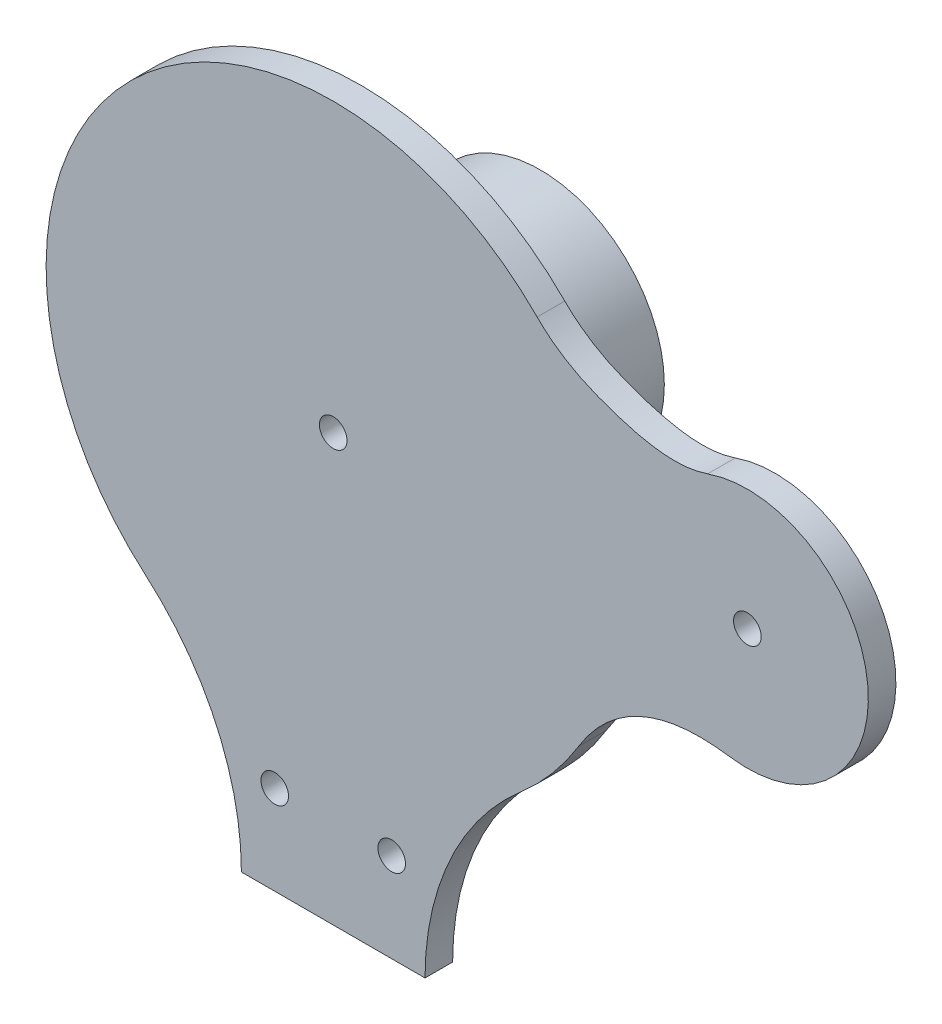
from build123d import *

# Parameters (mm, degrees)
SKETCH1_R           = 2.54
BOSS_EXTRUDE1_DEPTH = 5.08
SKETCH2_R           = 22.825529453
BOSS_EXTRUDE2_DEPTH = 33.02
SKETCH3_R           = 2.54
CUT_EXTRUDE1_DEPTH  = 39.1
BOSS_EXTRUDE3_DEPTH = 5.08
SKETCH5_R           = 2.54
CUT_EXTRUDE2_DEPTH  = 39.1


with BuildPart() as part:
    # Sketch1 → Boss-Extrude1 (new body)
    with BuildSketch(Plane.XY):
        with BuildLine():
            Line((-16.891, -131.282672274), (16.891, -131.282672274))
            ThreePointArc((16.891, -131.282672274), (19.601252021, -114.911473805), (27.442816508, -100.287128633))
            ThreePointArc((27.442816508, -100.287128633), (30.785280347, -96.37410804), (34.5064888, -92.819336271))
            ThreePointArc((34.5064888, -92.819336271), (0, 0), (-34.5064888, -92.819336271))
            ThreePointArc((-34.5064888, -92.819336271), (-30.785280347, -96.37410804), (-27.442816508, -100.287128633))
            ThreePointArc((-27.442816508, -100.287128633), (-19.601252021, -114.911473805), (-16.891, -131.282672274))
        make_face()
        with Locations((-10.756405179, -114.872047193)):
            Circle(SKETCH1_R, mode=Mode.SUBTRACT)
        with Locations((10.756405179, -114.872047193)):
            Circle(SKETCH1_R, mode=Mode.SUBTRACT)
    extrude(amount=BOSS_EXTRUDE1_DEPTH)

    # Sketch2 → Boss-Extrude2 (add)
    with BuildSketch(Plane(origin=(0, 0, 0), x_dir=(-1, 0, 0), z_dir=(0, 0, -1))):
        with Locations((0, -52.823729134)):
            Circle(SKETCH2_R)
    extrude(amount=BOSS_EXTRUDE2_DEPTH)

    # Sketch3 → Cut-Extrude1 (cut, through all)
    with BuildSketch(Plane(origin=(0, 0, -33.02), x_dir=(-1, 0, 0), z_dir=(0, 0, -1))):
        with Locations((0, -52.823729134)):
            Circle(SKETCH3_R)
    extrude(amount=-CUT_EXTRUDE1_DEPTH, mode=Mode.SUBTRACT)

    # Sketch4 → Boss-Extrude3 (add)
    with BuildSketch(Plane.XY.offset(5.08)):
        with BuildLine():
            ThreePointArc((45.161811227, -80.223677424), (52.45816234, -46.619894549), (37.524583334, -15.645079276))
            add(Edge.make_bspline(
                [(37.524583334, -15.645079276), (41.569282444, -19.727412804), (51.389708048, -24.415182371), (63.297197231, -26.895437115), (68.900180003, -24.949874899)],
                knots=[0, 0, 0, 0, 0.479929933, 1, 1, 1, 1], degree=3))
            ThreePointArc((68.900180003, -24.949874899), (98.354072, -43.866775297), (72.9914133, -67.993864183))
            add(Edge.make_bspline(
                [(45.161811227, -80.223677424), (47.574313167, -76.247284621), (55.033388576, -68.640688731), (65.508215076, -66.903538588), (72.9914133, -67.993864183)],
                knots=[0, 0, 0, 0, 0.395495141, 1, 1, 1, 1], degree=3))
        make_face()
    extrude(amount=-BOSS_EXTRUDE3_DEPTH)

    # Sketch5 → Cut-Extrude2 (cut, through all)
    with BuildSketch(Plane.XY.offset(5.08)):
        with Locations((76.2, -45.972469461)):
            Circle(SKETCH5_R)
    extrude(amount=-CUT_EXTRUDE2_DEPTH, mode=Mode.SUBTRACT)


solid = part.part
